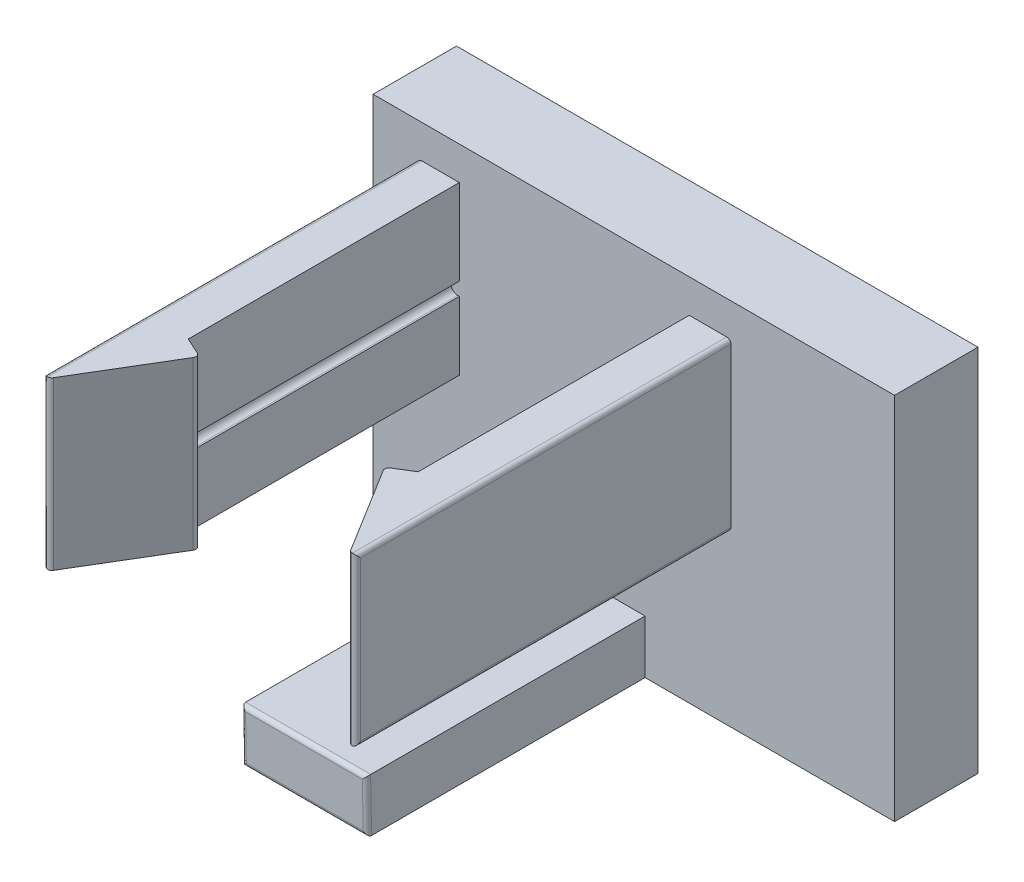
from build123d import *

# Parameters (mm, degrees)
SKETCH1_W           = 15.875
SKETCH1_H           = 11.239799379
BOSS_EXTRUDE1_DEPTH = 2.54
BOSS_EXTRUDE2_REACH = 31.638
SKETCH2_W           = 1.27
SKETCH2_H           = 5.08
SKETCH2_W_2         = 3.81
SKETCH2_H_2         = 1.624267758
BOSS_EXTRUDE3_REACH = 23.94
FILLET1_R           = 0.127


with BuildPart() as part:
    # Sketch1 → Boss-Extrude1 (new body)
    with BuildSketch(Plane.XY):
        with Locations((7.9375, -19.278367991)):
            Rectangle(SKETCH1_W, SKETCH1_H)
    extrude(amount=BOSS_EXTRUDE1_DEPTH)

    # Boss-Extrude2: up to this plane
    boss_extrude2_end = Plane(origin=(1.6499976, -12.666472126, 11.206213123), z_dir=(-1.2251589112771177e-15, 0.017452406437284806, -0.9998476951563913))
    # Sketch2 → Boss-Extrude2 (add, up to the surface)
    with BuildSketch(Plane.XY.offset(2.54), mode=Mode.PRIVATE) as boss_extrude2_sk1:
        with BuildLine():
            Line((2.625, -17.673999922), (2.625, -19.753999922))
            Line((2.625, -19.753999922), (1.355, -19.753999922))
            Line((1.355, -19.753999922), (1.355, -14.673999922))
            Line((1.355, -14.673999922), (2.625, -14.673999922))
            Line((2.625, -14.673999922), (2.625, -17.273999922))
            Line((2.625, -17.273999922), (2.375, -17.273999922))
            Line((2.375, -17.273999922), (2.375, -17.473999922))
            ThreePointArc((2.375, -17.473999922), (2.433578644, -17.615421279), (2.575, -17.673999922))
            Line((2.575, -17.673999922), (2.625, -17.673999922))
        make_face()
    boss_extrude2_tool1 = split(extrude(boss_extrude2_sk1.sketch, amount=BOSS_EXTRUDE2_REACH, mode=Mode.PRIVATE), bisect_by=boss_extrude2_end, keep=Keep.BOTH, mode=Mode.PRIVATE)
    add(boss_extrude2_tool1.solids().sort_by_distance((1.982561, -17.210473, 2.54))[0])
    # Sketch2 → Boss-Extrude2 (add, up to the surface)
    with BuildSketch(Plane.XY.offset(2.54), mode=Mode.PRIVATE) as boss_extrude2_sk2:
        with Locations((10.26, -17.213999922)):
            Rectangle(SKETCH2_W, SKETCH2_H)
    boss_extrude2_tool2 = split(extrude(boss_extrude2_sk2.sketch, amount=BOSS_EXTRUDE2_REACH, mode=Mode.PRIVATE), bisect_by=boss_extrude2_end, keep=Keep.BOTH, mode=Mode.PRIVATE)
    add(boss_extrude2_tool2.solids().sort_by_distance((10.26, -17.214, 2.54))[0])
    # Sketch2 → Boss-Extrude2 (add, up to the surface)
    with BuildSketch(Plane.XY.offset(2.54), mode=Mode.PRIVATE) as boss_extrude2_sk3:
        with Locations((6.375, -24.086133801)):
            Rectangle(SKETCH2_W_2, SKETCH2_H_2)
    boss_extrude2_tool3 = split(extrude(boss_extrude2_sk3.sketch, amount=BOSS_EXTRUDE2_REACH, mode=Mode.PRIVATE), bisect_by=boss_extrude2_end, keep=Keep.BOTH, mode=Mode.PRIVATE)
    add(boss_extrude2_tool3.solids().sort_by_distance((6.375, -24.086134, 2.54))[0])

    # Boss-Extrude3: up to this face of the body (flat: up to its plane)
    boss_extrude3_end = Plane(part.part.faces().sort_by_distance((1.99, -19.753999922, 6.811249933))[0])
    # Sketch4 → Boss-Extrude3 (add, up to the picked face)
    with BuildSketch(Plane.XZ.offset(14.673999922), mode=Mode.PRIVATE) as boss_extrude3_sk1:
        Polygon((10.895, 11.082499866), (9.625, 11.082499866), (9.625, 10.790559516), (8.992585474, 11.181716662), (10.895, 14.257499866), align=None)
    boss_extrude3_tool1 = split(extrude(boss_extrude3_sk1.sketch, amount=BOSS_EXTRUDE3_REACH, mode=Mode.PRIVATE), bisect_by=boss_extrude3_end, keep=Keep.BOTH, mode=Mode.PRIVATE)
    # Sketch4 → Boss-Extrude3 (add, up to the picked face)
    with BuildSketch(Plane.XZ.offset(14.673999922), mode=Mode.PRIVATE) as boss_extrude3_sk2:
        Polygon((1.355, 11.082499866), (2.625, 11.082499866), (2.625, 10.790559516), (3.26, 11.082499866), (1.355, 14.257499866), align=None)
    boss_extrude3_tool2 = split(extrude(boss_extrude3_sk2.sketch, amount=BOSS_EXTRUDE3_REACH, mode=Mode.PRIVATE), bisect_by=boss_extrude3_end, keep=Keep.BOTH, mode=Mode.PRIVATE)
    add(boss_extrude3_tool1.solids().sort_by(Axis((10.227849, -14.674, 12.119311), (0, -1, 0)))[0])
    add(boss_extrude3_tool2.solids().sort_by(Axis((2.015179, -14.674, 12.106466), (0, -1, 0)))[0])

    # Fillet1
    fillet1_edges = [part.edges().sort_by_distance(p)[0] for p in [
        (10.895, -14.673999922, 8.398749933),
        (10.895, -19.753999922, 8.398749933),
        (1.355, -19.753999922, 8.398749933),
        (1.355, -14.673999922, 8.398749933),
        (6.375, -23.273999922, 11.021058037),
        (8.28, -24.086133801, 11.006882187),
        (6.375, -24.89826768, 10.992706338),
        (4.47, -24.086133801, 11.006882187),
        (8.992585474, -17.213999922, 11.181716662),
        (10.895, -17.213999922, 14.257499866),
        (1.355, -17.213999922, 14.257499866),
        (3.26, -17.213999922, 11.082499866),
    ]]
    fillet(fillet1_edges, radius=FILLET1_R)


solid = part.part
